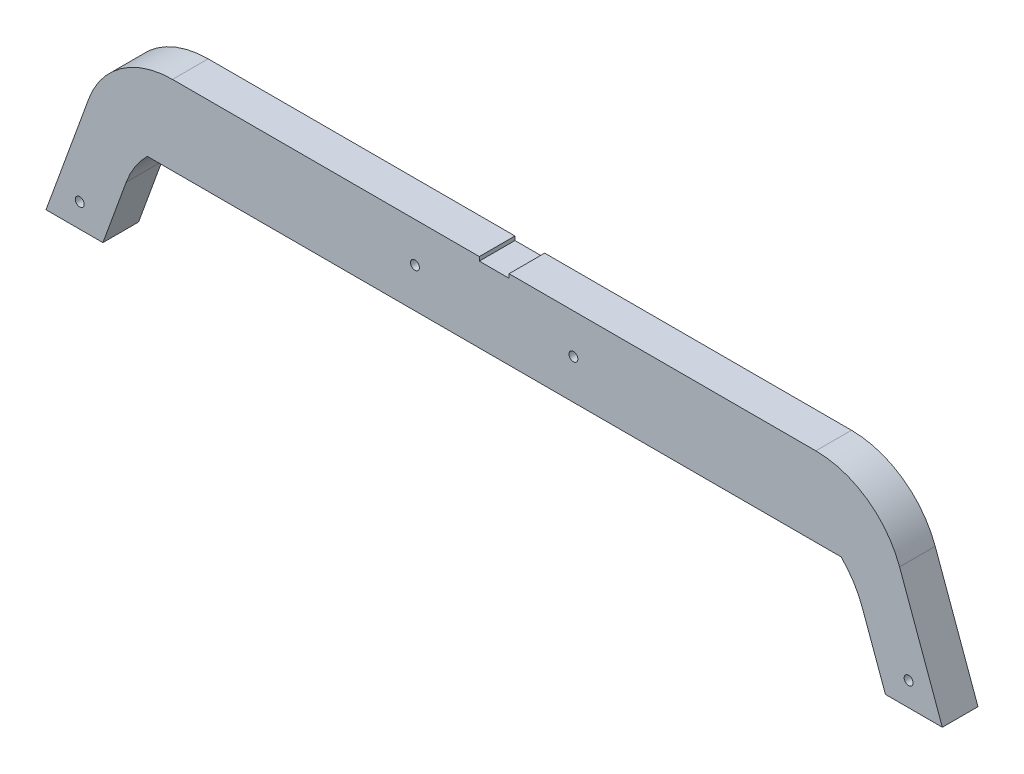
from build123d import *

# Parameters (mm, degrees)
SALIENTE_EXTRUIR1_DEPTH = 40
REDONDEO1_R             = 100
ESCALA1_SCALE           = 0.6
ESCALA2_SCALE           = 0.75
SALIENTE_EXTRUIR2_DEPTH = 18
CROQUIS3_W              = 15
CROQUIS3_H              = 2
CORTAR_EXTRUIR1_DEPTH   = 19
CROQUIS4_R              = 2.25
CORTAR_EXTRUIR3_DEPTH   = 19
CROQUIS5_R              = 2.25
CORTAR_EXTRUIR4_DEPTH   = 19


with BuildPart() as part:
    # Croquis1 → Saliente-Extruir1 (new body)
    with BuildSketch(Plane.XY):
        Polygon((-439, 0), (-388.899497253, 137.65), (388.899497253, 137.65), (439, 0), (502.850666349, 0), (495.381557247, 20.5212086), (430.911949546, 197.65), (-430.911949546, 197.65), (-495.381557247, 20.5212086), (-502.850666349, 0), align=None)
    extrude(amount=SALIENTE_EXTRUIR1_DEPTH)

    # Redondeo1
    redondeo1_edges = [part.edges().sort_by_distance(p)[0] for p in [
        (-430.911949546, 197.65, 20),
        (430.911949546, 197.65, 20),
        (388.899497253, 137.65, 20),
        (-388.899497253, 137.65, 20),
    ]]
    fillet(redondeo1_edges, radius=REDONDEO1_R)


with BuildPart() as part_1:
    # Escala1: scaled about (0, 141.339436806, 20)
    add(part.part.scale(ESCALA1_SCALE).moved(Location((0, 56.535774722, 8))))


with BuildPart() as part_2:
    # Escala2: scaled about (0, 141.339436806, 20)
    add(part_1.part.scale(ESCALA2_SCALE).moved(Location((0, 35.334859202, 5))))

    # Croquis2 → Saliente-Extruir2 (add, through all)
    with BuildSketch(Plane.XY.offset(29)):
        with BuildLine():
            Line((-111.856850505, 126.679190243), (111.856850505, 126.679190243))
            Line((111.856850505, 126.679190243), (175.134018584, 126.679190243))
            ThreePointArc((175.134018584, 126.679190243), (160.598065921, 136.30250102), (143.495434545, 139.679190243))
            Line((143.495434545, 139.679190243), (-143.495434545, 139.679190243))
            ThreePointArc((-143.495434545, 139.679190243), (-160.598065921, 136.30250102), (-175.134018584, 126.679190243))
            Line((-175.134018584, 126.679190243), (-111.856850505, 126.679190243))
        make_face()
    extrude(amount=-SALIENTE_EXTRUIR2_DEPTH)

    # Croquis3 → Cortar-Extruir1 (cut, through all)
    with BuildSketch(Plane.XY.offset(29)):
        with Locations((0, 165.679190243)):
            Rectangle(CROQUIS3_W, CROQUIS3_H)
    extrude(amount=-CORTAR_EXTRUIR1_DEPTH, mode=Mode.SUBTRACT)

    # Croquis4 → Cortar-Extruir3 (cut, through all)
    with BuildSketch(Plane.XY.offset(29)):
        with Locations((209.25, 89.736690243)):
            Circle(CROQUIS4_R)
        with Locations((-209.25, 89.736690243)):
            Circle(CROQUIS4_R)
    extrude(amount=-CORTAR_EXTRUIR3_DEPTH, mode=Mode.SUBTRACT)

    # Croquis5 → Cortar-Extruir4 (cut, through all)
    with BuildSketch(Plane.XY.offset(29)):
        with Locations((-40, 146.679190243)):
            Circle(CROQUIS5_R)
        with Locations((40, 146.679190243)):
            Circle(CROQUIS5_R)
    extrude(amount=-CORTAR_EXTRUIR4_DEPTH, mode=Mode.SUBTRACT)


solid = part_2.part
